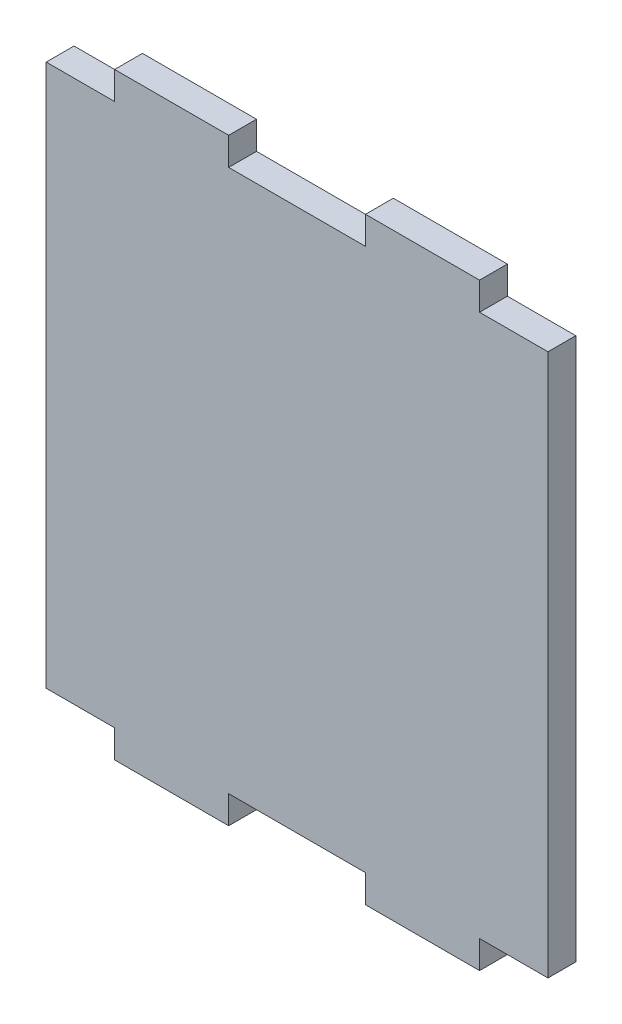
from build123d import *

# Parameters (mm, degrees)
SALIENTE_EXTRUIR1_DEPTH = 2.44


with BuildPart() as part:
    # Croquis1 → Saliente-Extruir1 (new body)
    with BuildSketch(Plane.XY):
        Polygon((-22, -23.78), (-16, -23.78), (-16, -26.22), (-6, -26.22), (-6, -23.78), (6, -23.78), (6, -26.22), (16, -26.22), (16, -23.78), (22, -23.78), (22, 23.78), (16, 23.78), (16, 26.22), (6, 26.22), (6, 23.78), (-6, 23.78), (-6, 26.22), (-16, 26.22), (-16, 23.78), (-22, 23.78), align=None)
    extrude(amount=SALIENTE_EXTRUIR1_DEPTH)


solid = part.part
